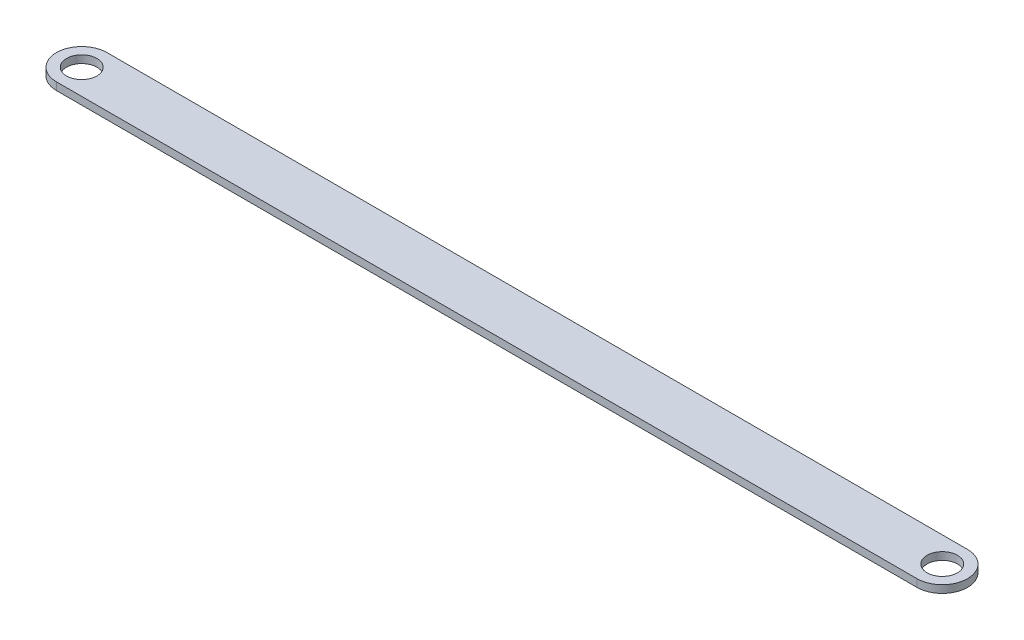
from build123d import *

# Parameters (mm, degrees)
SKETCH1_R           = 6
BOSS_EXTRUDE1_DEPTH = 3


with BuildPart() as part:
    # Sketch1 → Boss-Extrude1 (new body)
    with BuildSketch(Plane(origin=(0, 0, 0), x_dir=(1, 0, 0), z_dir=(0, 1, 0))):
        with BuildLine():
            Line((-62.687563754, 15.857142857), (277.312436246, 15.857142857))
            ThreePointArc((277.312436246, 15.857142857), (287.312436246, 5.857142857), (277.312436246, -4.142857143))
            Line((277.312436246, -4.142857143), (-62.687563754, -4.142857143))
            ThreePointArc((-62.687563754, -4.142857143), (-72.687563754, 5.857142857), (-62.687563754, 15.857142857))
        make_face()
        with Locations((-62.687563754, 5.857142857)):
            Circle(SKETCH1_R, mode=Mode.SUBTRACT)
        with Locations((277.312436246, 5.857142857)):
            Circle(SKETCH1_R, mode=Mode.SUBTRACT)
    extrude(amount=BOSS_EXTRUDE1_DEPTH)


solid = part.part
